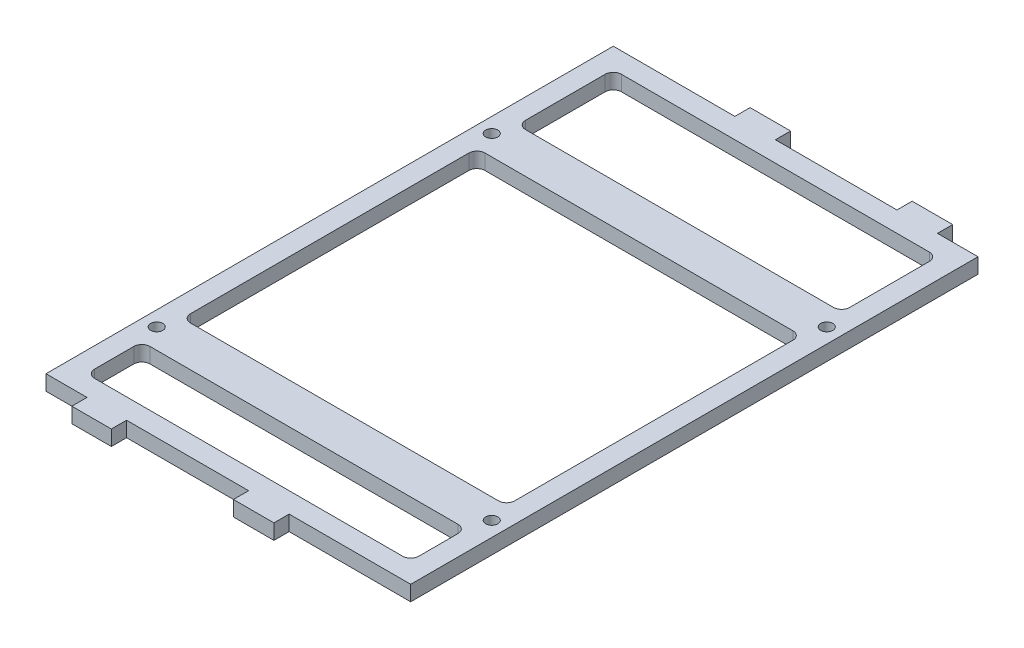
from build123d import *

# Parameters (mm, degrees)
SKETCH1_W                 = 114.3
SKETCH1_H                 = 177.8
SKETCH1_W_2               = 101.6
SKETCH1_H_2               = 165.1
BOSS_EXTRUDE1_DEPTH       = 4.7625
SKETCH2_W                 = 12.38677804
SKETCH2_H                 = 4.7625
SKETCH2_W_2               = 12.7
BOSS_EXTRUDE2_DEPTH       = 4.7625
SKETCH3_W                 = 12.7
SKETCH3_H                 = 4.7625
BOSS_EXTRUDE3_DEPTH       = 4.7625
FILLET1_R                 = 2.54
SKETCH4_W                 = 114.3
SKETCH4_H                 = 12.7
BOSS_EXTRUDE4_DEPTH       = 4.7625
F_6_CLEARANCE_HOLE1_D     = 3.7973
F_6_CLEARANCE_HOLE1_DEPTH = 25.4
F_6_CLEARANCE_HOLE1_TIP   = 1.140824014
FILLET2_R                 = 2.54


with BuildPart() as part:
    # Sketch1 → Boss-Extrude1 (new body)
    with BuildSketch(Plane(origin=(0, 0, 0), x_dir=(1, 0, 0), z_dir=(0, 1, 0))):
        Rectangle(SKETCH1_W, SKETCH1_H)
        Rectangle(SKETCH1_W_2, SKETCH1_H_2, mode=Mode.SUBTRACT)
    extrude(amount=BOSS_EXTRUDE1_DEPTH)

    # Sketch2 → Boss-Extrude2 (add)
    with BuildSketch(Plane.XY.offset(88.9)):
        with Locations((-38.1, 2.38125)):
            Rectangle(SKETCH2_W, SKETCH2_H)
        with Locations((12.7, 2.38125)):
            Rectangle(SKETCH2_W_2, SKETCH2_H)
    extrude(amount=BOSS_EXTRUDE2_DEPTH)

    # Sketch3 → Boss-Extrude3 (add)
    with BuildSketch(Plane(origin=(0, 0, -88.9), x_dir=(-1, 0, 0), z_dir=(0, 0, -1))):
        with Locations((-38.1, 2.38125)):
            Rectangle(SKETCH3_W, SKETCH3_H)
        with Locations((12.7, 2.38125)):
            Rectangle(SKETCH3_W, SKETCH3_H)
    extrude(amount=BOSS_EXTRUDE3_DEPTH)

    # Fillet1
    fillet1_edges = [part.edges().sort_by_distance(p)[0] for p in [
        (50.8, 2.38125, 82.55),
        (50.8, 2.38125, -82.55),
        (-50.8, 2.38125, -82.55),
        (-50.8, 2.38125, 82.55),
    ]]
    fillet(fillet1_edges, radius=FILLET1_R)

    # Sketch4 → Boss-Extrude4 (add)
    with BuildSketch(Plane(origin=(0, 4.7625, 0), x_dir=(1, 0, 0), z_dir=(0, 1, 0))):
        with Locations((0, 46.149999902)):
            Rectangle(SKETCH4_W, SKETCH4_H)
        with Locations((0, -58.849999902)):
            Rectangle(SKETCH4_W, SKETCH4_H)
    extrude(amount=-BOSS_EXTRUDE4_DEPTH)

    # #6 Clearance Hole1
    with Locations(Plane(origin=(0, 4.7625, 0), x_dir=(-1, 0, 0), z_dir=(0, 1, 0))):
        with Locations((52.5, -46.149999902), (-52.5, -46.149999902), (52.5, 58.849999902), (-52.5, 58.849999902)):
            Hole(F_6_CLEARANCE_HOLE1_D / 2, depth=F_6_CLEARANCE_HOLE1_DEPTH)
            with Locations((0, 0, -(F_6_CLEARANCE_HOLE1_DEPTH + F_6_CLEARANCE_HOLE1_TIP / 2))):  # 118° drill point
                Cone(0, F_6_CLEARANCE_HOLE1_D / 2, F_6_CLEARANCE_HOLE1_TIP, mode=Mode.SUBTRACT)

    # Fillet2
    fillet2_edges = [part.edges().sort_by_distance(p)[0] for p in [
        (-50.8, 2.38125, -39.799999902),
        (-50.8, 2.38125, -52.499999902),
        (50.8, 2.38125, -52.499999902),
        (50.8, 2.38125, -39.799999902),
        (-50.8, 2.38125, 65.199999902),
        (-50.8, 2.38125, 52.499999902),
        (50.8, 2.38125, 52.499999902),
        (50.8, 2.38125, 65.199999902),
    ]]
    fillet(fillet2_edges, radius=FILLET2_R)


solid = part.part
